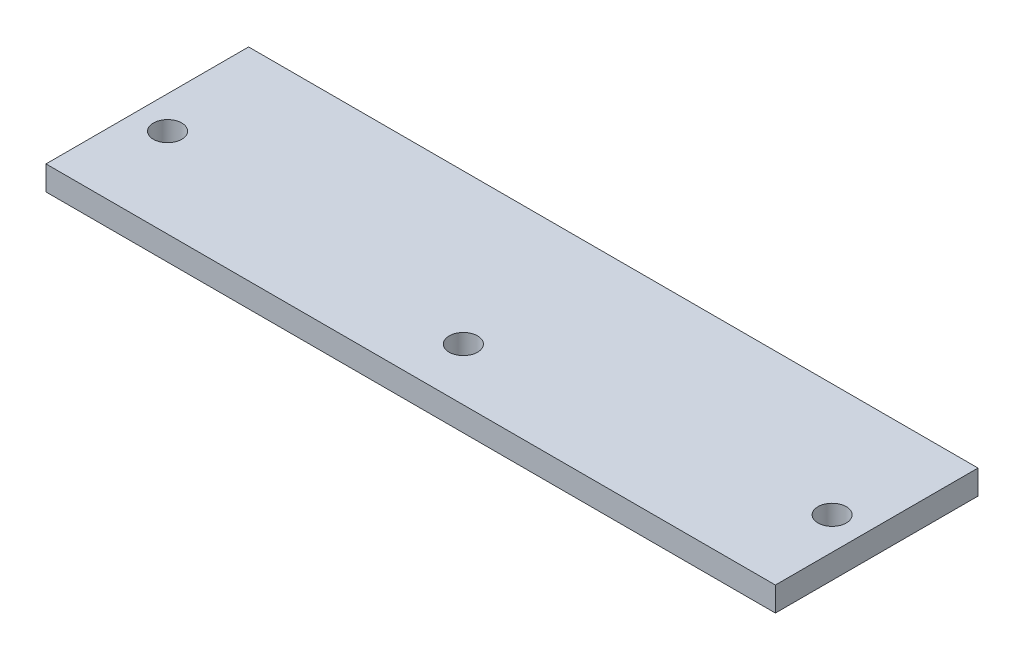
from build123d import *

# Parameters (mm, degrees)
ESQUISSE1_W        = 90
ESQUISSE1_H        = 25
ESQUISSE1_R        = 1.75
BOSS_EXTRU_1_DEPTH = 3


with BuildPart() as part:
    # Esquisse1 → Boss.-Extru.1 (new body)
    with BuildSketch(Plane(origin=(0, 0, 0), x_dir=(1, 0, 0), z_dir=(0, 1, 0))):
        Rectangle(ESQUISSE1_W, ESQUISSE1_H)
        with Locations((-41, -1.5)):
            Circle(ESQUISSE1_R, mode=Mode.SUBTRACT)
        with Locations((41, -1.5)):
            Circle(ESQUISSE1_R, mode=Mode.SUBTRACT)
        with Locations((0, -6)):
            Circle(ESQUISSE1_R, mode=Mode.SUBTRACT)
    extrude(amount=BOSS_EXTRU_1_DEPTH)


solid = part.part
